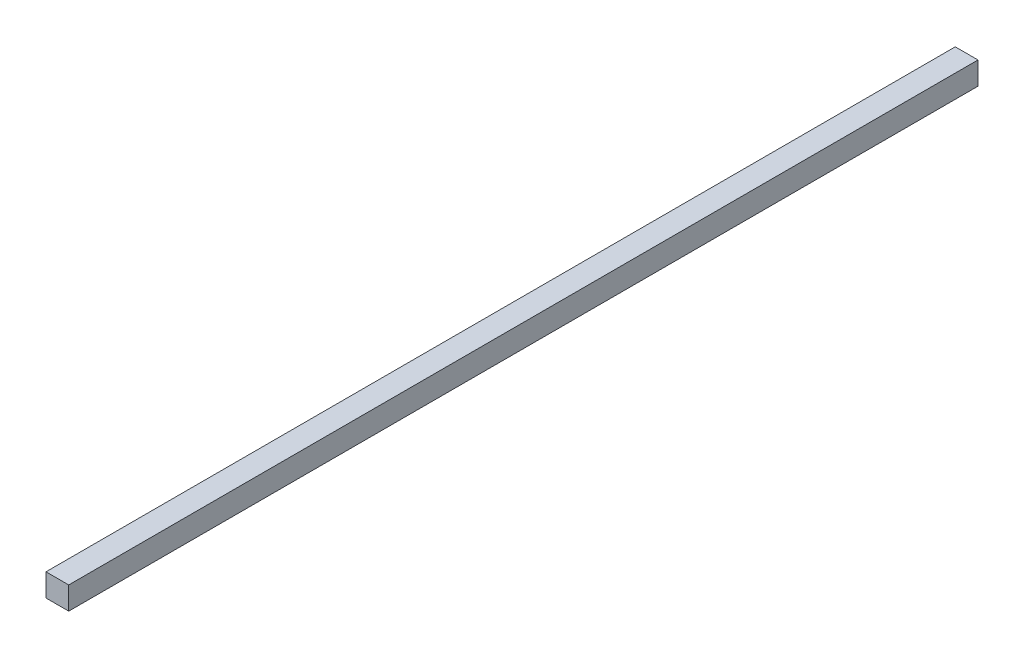
from build123d import *

# Parameters (mm, degrees)
SKETCH_1_W      = 20
SKETCH_1_H      = 20
EXTRUDE_1_DEPTH = 800


with BuildPart() as part:
    # 草图1 → 凸台-拉伸1 (new body)
    with BuildSketch(Plane.XY):
        Rectangle(SKETCH_1_W, SKETCH_1_H)
    extrude(amount=EXTRUDE_1_DEPTH)


solid = part.part
